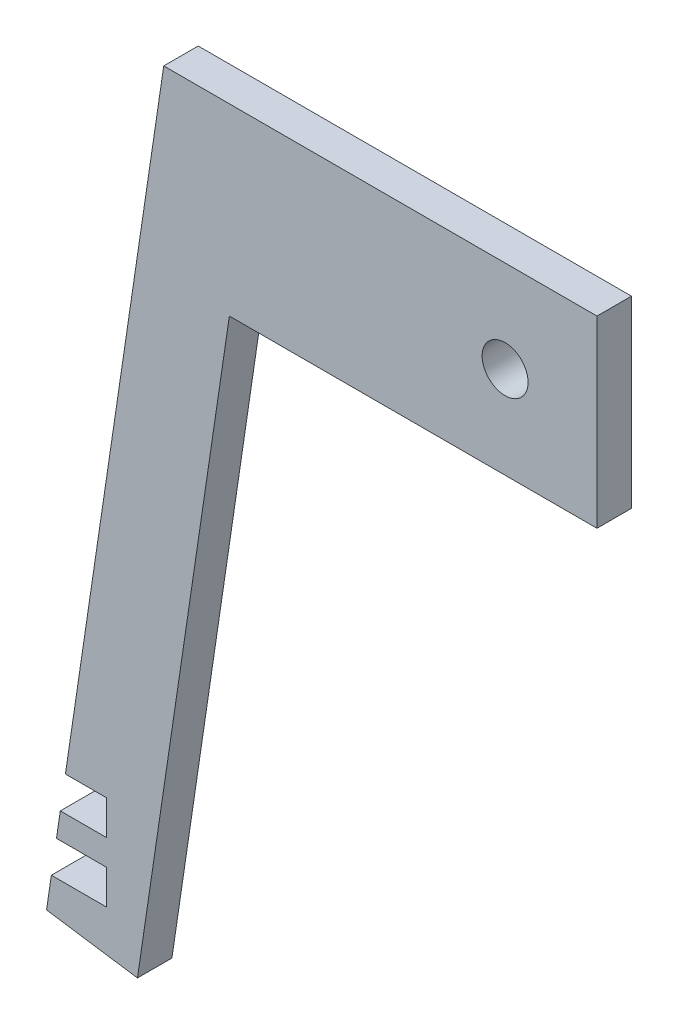
from build123d import *

# Parameters (mm, degrees)
SKETCH1_R           = 3.175
BOSS_EXTRUDE1_DEPTH = 4.7625


with BuildPart() as part:
    # Sketch1 → Boss-Extrude1 (new body)
    with BuildSketch(Plane.XY):
        Polygon((3.6307971, 110.966804989), (-9.955134074, 19.431), (-4.311994053, 19.431), (-4.311994053, 14.6685), (-10.661994053, 14.6685), (-11.189782837, 11.1125), (-4.311994053, 11.1125), (-4.311994053, 6.35), (-11.896642817, 6.35), (-12.562384724, 1.864534804), (0, 0), (12.7, 85.566804989), (63.5, 85.566804989), (63.5, 110.966804989), align=None)
        with Locations((50.8, 98.266804989)):
            Circle(SKETCH1_R, mode=Mode.SUBTRACT)
    extrude(amount=BOSS_EXTRUDE1_DEPTH)


solid = part.part
